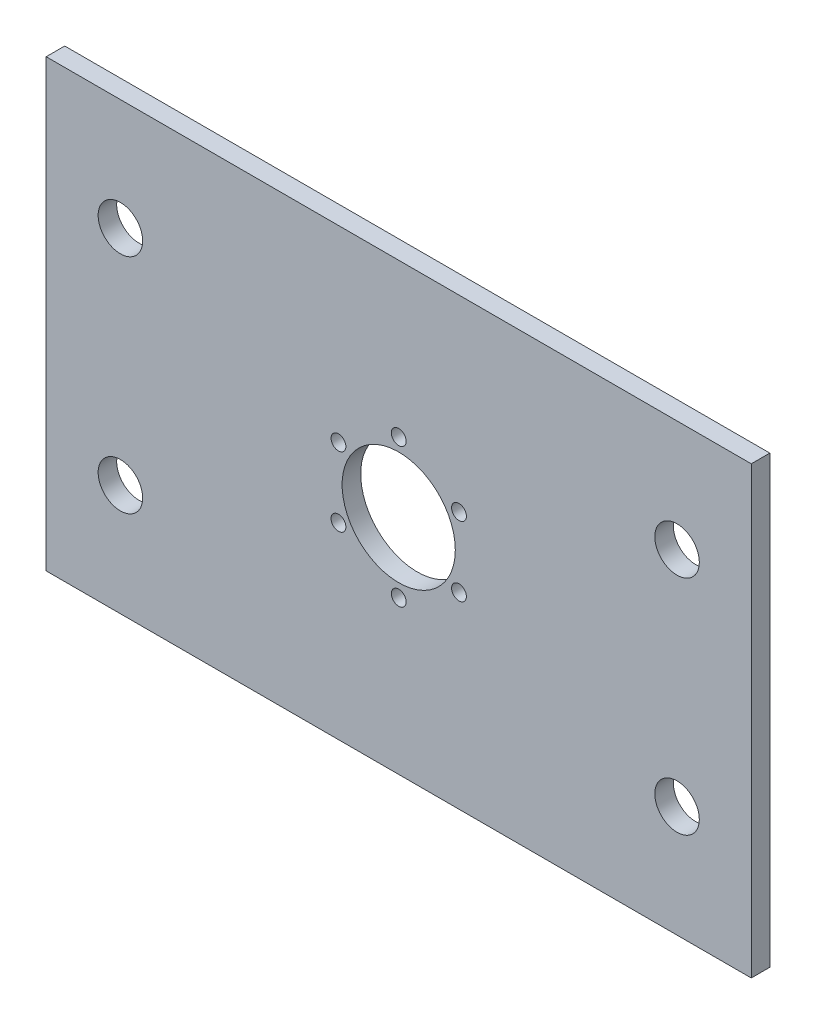
from build123d import *

# Parameters (mm, degrees)
SKETCH1_W           = 190
SKETCH1_H           = 120
SKETCH1_R           = 6
SKETCH1_R_2         = 15.25
SKETCH1_R_3         = 2
BOSS_EXTRUDE1_DEPTH = 5


with BuildPart() as part:
    # Sketch1 → Boss-Extrude1 (new body)
    with BuildSketch(Plane.XY):
        Rectangle(SKETCH1_W, SKETCH1_H)
        with Locations((-75, 30)):
            Circle(SKETCH1_R, mode=Mode.SUBTRACT)
        with Locations((75, 30)):
            Circle(SKETCH1_R, mode=Mode.SUBTRACT)
        with Locations((75, -30)):
            Circle(SKETCH1_R, mode=Mode.SUBTRACT)
        with Locations((-75, -30)):
            Circle(SKETCH1_R, mode=Mode.SUBTRACT)
        Circle(SKETCH1_R_2, mode=Mode.SUBTRACT)
        with Locations((0, 18.75)):
            Circle(SKETCH1_R_3, mode=Mode.SUBTRACT)
        with Locations((16.237976321, 9.375)):
            Circle(SKETCH1_R_3, mode=Mode.SUBTRACT)
        with Locations((16.237976321, -9.375)):
            Circle(SKETCH1_R_3, mode=Mode.SUBTRACT)
        with Locations((0, -18.75)):
            Circle(SKETCH1_R_3, mode=Mode.SUBTRACT)
        with Locations((-16.237976321, -9.375)):
            Circle(SKETCH1_R_3, mode=Mode.SUBTRACT)
        with Locations((-16.237976321, 9.375)):
            Circle(SKETCH1_R_3, mode=Mode.SUBTRACT)
    extrude(amount=BOSS_EXTRUDE1_DEPTH)


solid = part.part
